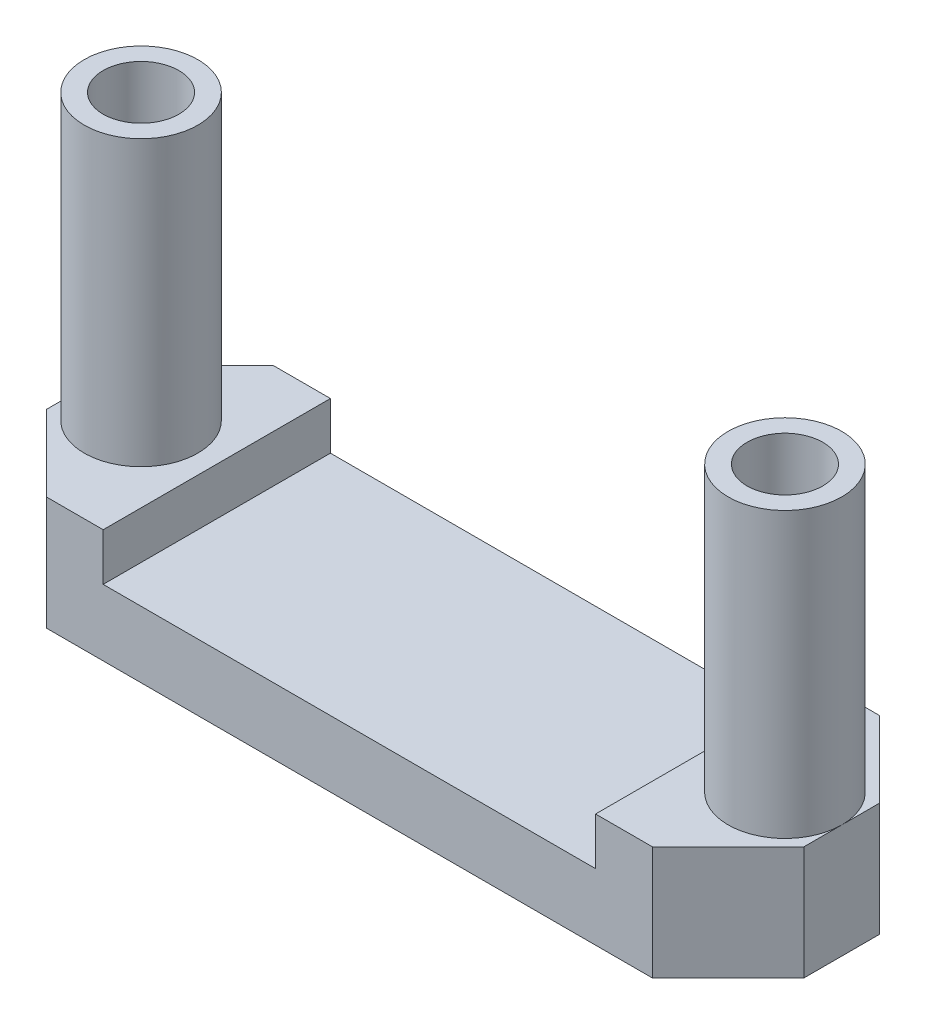
from build123d import *

# Parameters (mm, degrees)
SKETCH1_W           = 20
SKETCH1_H           = 6
SKETCH1_R           = 1
BOSS_EXTRUDE1_DEPTH = 3
SKETCH2_W           = 13
SKETCH2_H           = 6
CUT_EXTRUDE1_DEPTH  = 1.25
CHAMFER1_SIZE       = 2
SKETCH3_R           = 1.5
SKETCH3_R_2         = 1
BOSS_EXTRUDE2_DEPTH = 7.5


with BuildPart() as part:
    # Sketch1 → Boss-Extrude1 (new body)
    with BuildSketch(Plane(origin=(0, 0, 0), x_dir=(1, 0, 0), z_dir=(0, 1, 0))):
        Rectangle(SKETCH1_W, SKETCH1_H)
        with Locations((-8.5, 0)):
            Circle(SKETCH1_R, mode=Mode.SUBTRACT)
        with Locations((8.5, 0)):
            Circle(SKETCH1_R, mode=Mode.SUBTRACT)
    extrude(amount=BOSS_EXTRUDE1_DEPTH)

    # Sketch2 → Cut-Extrude1 (cut)
    with BuildSketch(Plane(origin=(0, 3, 0), x_dir=(1, 0, 0), z_dir=(0, 1, 0))):
        Rectangle(SKETCH2_W, SKETCH2_H)
    extrude(amount=-CUT_EXTRUDE1_DEPTH, mode=Mode.SUBTRACT)

    # Chamfer1
    chamfer1_edges = [part.edges().sort_by_distance(p)[0] for p in [
        (10, 1.5, 3),
        (-10, 1.5, 3),
        (-10, 1.5, -3),
        (10, 1.5, -3),
    ]]
    chamfer(chamfer1_edges, length=CHAMFER1_SIZE)

    # Sketch3 → Boss-Extrude2 (add)
    with BuildSketch(Plane(origin=(0, 3, 0), x_dir=(1, 0, 0), z_dir=(0, 1, 0))):
        with Locations((-8.5, 0)):
            Circle(SKETCH3_R)
        with Locations((-8.5, 0)):
            Circle(SKETCH3_R_2, mode=Mode.SUBTRACT)
    boss_extrude2 = extrude(amount=BOSS_EXTRUDE2_DEPTH)

    # Mirror1: Boss-Extrude2 across plane
    add(boss_extrude2.mirror(Plane(origin=(0, 0, 0), x_dir=(0, 0, 1), z_dir=(1, 0, 0))))


solid = part.part
